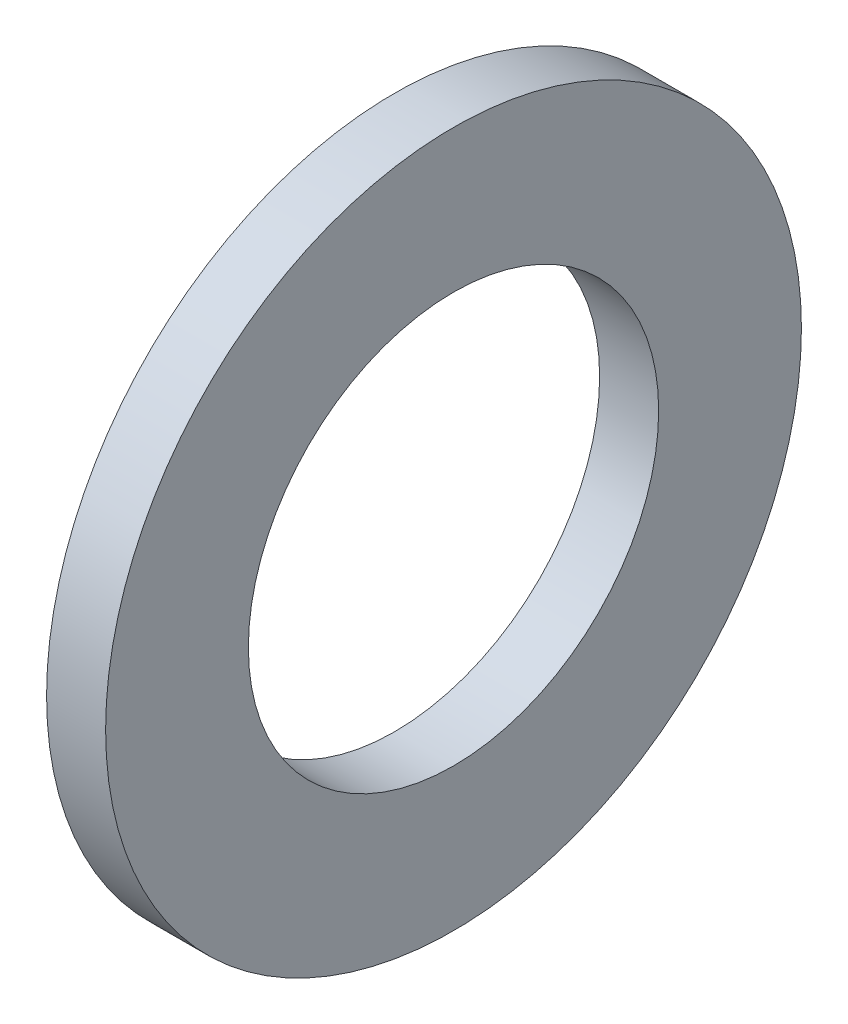
from build123d import *

# Parameters (mm, degrees)
SKETCH1_W = 5.6
SKETCH1_H = 13.54


with BuildPart() as part:
    # Sketch1 → Base-Revolve (revolve)
    with BuildSketch(Plane.XY):
        with Locations((-2.8, 26.23)):
            Rectangle(SKETCH1_W, SKETCH1_H)
    revolve(axis=Axis((-34.925, 0, 0), (1, 0, 0)))


solid = part.part
